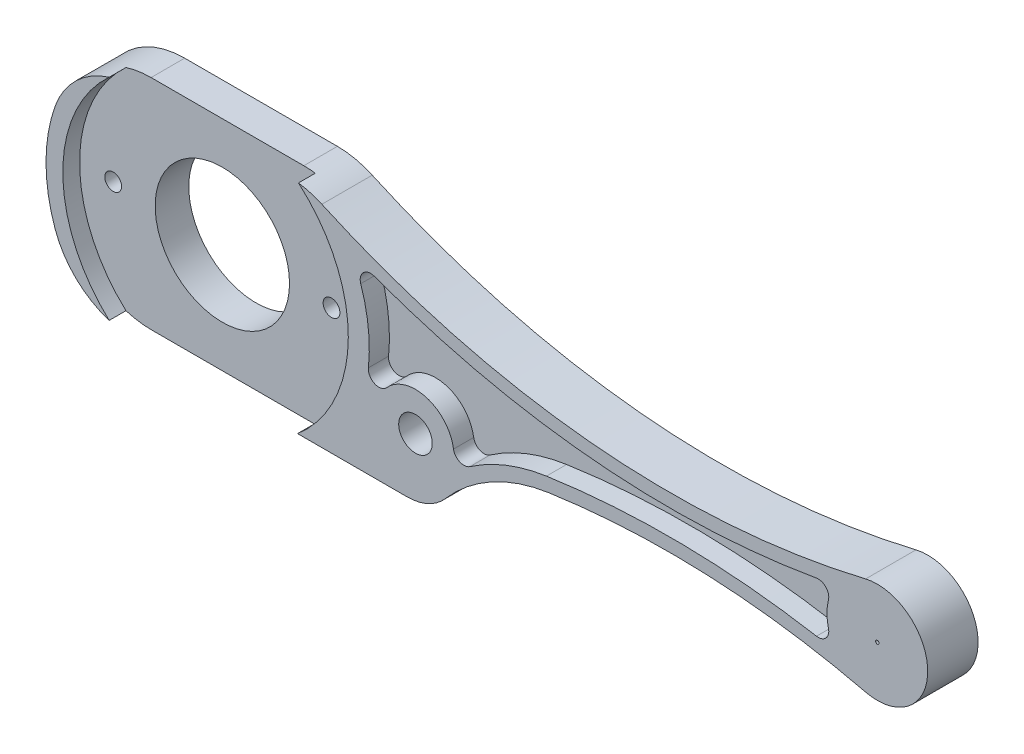
from build123d import *

# Parameters (mm, degrees)
SKIZZE1_W                       = 70
SKIZZE1_H                       = 30
SKIZZE1_R                       = 4
SKIZZE1_R_2                     = 0.1
LINEAR_AUSTRAGEN1_DEPTH         = 3
F_1_0_1_DIAMETER_HOLE1_D        = 1
F_2_0_2_DIAMETER_HOLE1_D        = 2
SKIZZE7_R                       = 8.5
SCHNITT_LINEAR_AUSTRAGEN1_DEPTH = 1
SKIZZE8_OUTSIDE_W               = 87.244
SKIZZE8_OUTSIDE_H               = 47.244
SCHNITT_LINEAR_AUSTRAGEN2_DEPTH = 58.087651905
SCHNITT_LINEAR_AUSTRAGEN3_DEPTH = 1.2


with BuildPart() as part:
    # Skizze1 → Linear austragen1 (new body)
    with BuildSketch(Plane.XY):
        with Locations((20, 0)):
            Rectangle(SKIZZE1_W, SKIZZE1_H)
        Circle(SKIZZE1_R, mode=Mode.SUBTRACT)
        with Locations((40, 0)):
            Circle(SKIZZE1_R_2, mode=Mode.SUBTRACT)
    extrude(amount=LINEAR_AUSTRAGEN1_DEPTH)

    # Ø1.0 (1) Diameter Hole1 (through all)
    with Locations(Plane(origin=(0, 0, 0), x_dir=(-1, 0, 0), z_dir=(0, 0, -1))):
        with Locations((6.5, 0), (-6.5, 0)):
            Hole(F_1_0_1_DIAMETER_HOLE1_D / 2)

    # Ø2.0 (2) Diameter Hole1 (through all)
    with Locations(Plane(origin=(0, 0, 0), x_dir=(1, 0, 0), z_dir=(0, 0, -1))):
        with Locations((12.5, 3)):
            Hole(F_2_0_2_DIAMETER_HOLE1_D / 2)

    # Skizze7 → Schnitt-Linear austragen1 (cut)
    with BuildSketch(Plane.XY):
        Circle(SKIZZE7_R)
    extrude(amount=SCHNITT_LINEAR_AUSTRAGEN1_DEPTH, mode=Mode.SUBTRACT)

    # Skizze8 outside → Schnitt-Linear austragen2 (cut, through all)
    with BuildSketch(Plane.XY):
        with Locations((20, 0)):
            Rectangle(SKIZZE8_OUTSIDE_W, SKIZZE8_OUTSIDE_H)
        with BuildLine():
            Line((-4.242640687, 6.5), (4.850693198, 6.5))
            ThreePointArc((4.850693198, 6.5), (5.911913676, 6.386083411), (6.924777907, 6.049524439))
            ThreePointArc((6.924777907, 6.049524439), (22.851496839, 1.777066749), (39.30182783, 2.917628424))
            ThreePointArc((39.30182783, 2.917628424), (43, 0), (39.30182783, -2.917628424))
            ThreePointArc((39.30182783, -2.917628424), (29.897933333, -1.594625688), (20.413511825, -2.073495804))
            ThreePointArc((20.413511825, -2.073495804), (17.039126957, -3.208684673), (14.276292568, -5.454096248))
            ThreePointArc((14.276292568, -5.454096248), (13.252539671, -6.226012541), (12, -6.5))
            Line((12, -6.5), (-4.242640687, -6.5))
            ThreePointArc((-4.242640687, -6.5), (-7.129392033, -5.582482905), (-8.956685895, -3.166666667))
            ThreePointArc((-8.956685895, -3.166666667), (-9.5, 0), (-8.956685895, 3.166666667))
            ThreePointArc((-8.956685895, 3.166666667), (-7.129392033, 5.582482905), (-4.242640687, 6.5))
        make_face(mode=Mode.SUBTRACT)
    extrude(amount=SCHNITT_LINEAR_AUSTRAGEN2_DEPTH, mode=Mode.SUBTRACT)

    # Skizze10 → Schnitt-Linear austragen3 (cut)
    with BuildSketch(Plane.XY):
        with BuildLine():
            ThreePointArc((36.376629725, 1.49720748), (23.054109204, 0.954513618), (10.049282761, 3.89705654))
            ThreePointArc((10.049282761, 3.89705654), (9.397134344, 3.759216075), (9.240224203, 3.111391438))
            ThreePointArc((9.240224203, 3.111391438), (9.689735111, 1.082373999), (9.699012563, -0.995818907))
            ThreePointArc((9.699012563, -0.995818907), (10.068812364, -1.631628436), (10.787531238, -1.47526722))
            ThreePointArc((10.787531238, -1.47526722), (13.150598424, -0.801345638), (14.766431088, -2.652653724))
            ThreePointArc((14.766431088, -2.652653724), (15.136326342, -3.131711101), (15.73868827, -3.072731627))
            ThreePointArc((15.73868827, -3.072731627), (17.915226797, -1.915501516), (20.297478014, -1.281955435))
            ThreePointArc((20.297478014, -1.281955435), (28.345625064, -0.749320212), (36.376629725, -1.49720748))
            ThreePointArc((36.376629725, -1.49720748), (36.94164037, -1.30691696), (37.090043464, -0.729488148))
            ThreePointArc((37.090043464, -0.729488148), (37, 0), (37.090043464, 0.729488148))
            ThreePointArc((37.090043464, 0.729488148), (36.94164037, 1.30691696), (36.376629725, 1.49720748))
        make_face()
    extrude(amount=SCHNITT_LINEAR_AUSTRAGEN3_DEPTH, mode=Mode.SUBTRACT)


with BuildPart() as body_2:
    # Mirror1: mirrored copy
    add(part.part.mirror(Plane(origin=(-15, -15, 3), x_dir=(1, 0, 0), z_dir=(0, 0, 1))))


solid = body_2.part
